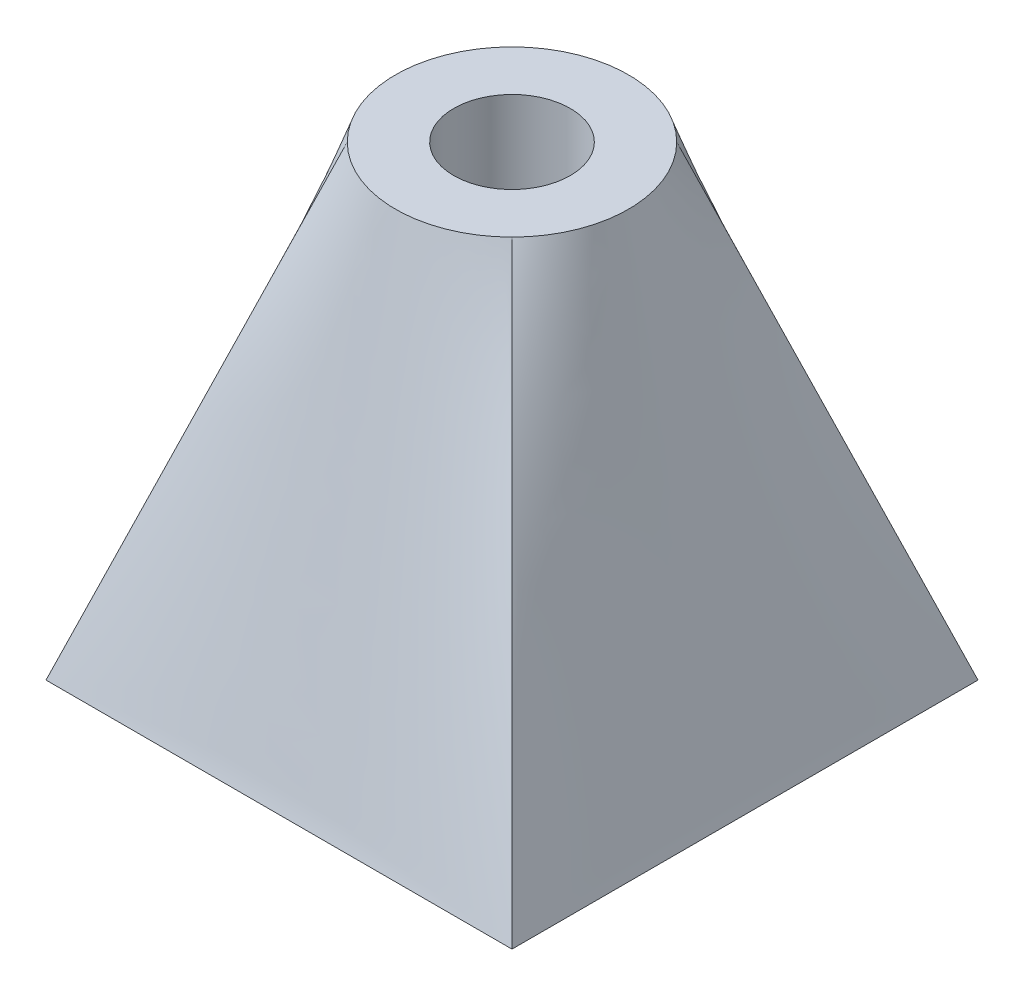
from build123d import *

# Parameters (mm, degrees)
SKETCH1_W          = 40
SKETCH1_H          = 40
SKETCH3_R          = 5
CUT_EXTRUDE1_DEPTH = 70.282032476


with BuildPart() as part:
    # Sketch1 → Loft1 section 0
    with BuildSketch(Plane(origin=(0, 0, 0), x_dir=(1, 0, 0), z_dir=(0, 1, 0))):
        with Locations((20, 20)):
            Rectangle(SKETCH1_W, SKETCH1_H)
    # Sketch2 for Loft1 → Loft1 section 1
    with BuildSketch(Plane(origin=(0, 40, 0), x_dir=(1, 0, 0), z_dir=(0, 1, 0))):
        with BuildLine():
            # circular arc as an exact rational Bezier (weights 1, cos(half-angle), 1)
            Bezier((12.928932188, 12.928932188), (20, 5.857864377), (27.071067812, 12.928932188), weights=[1, 0.707106781, 1])
            Bezier((27.071067812, 12.928932188), (34.142135623, 20), (27.071067812, 27.071067812), weights=[1, 0.707106781, 1])
            Bezier((27.071067812, 27.071067812), (20, 34.142135623), (12.928932188, 27.071067812), weights=[1, 0.707106781, 1])
            Bezier((12.928932188, 27.071067812), (5.857864377, 20), (12.928932188, 12.928932188), weights=[1, 0.707106781, 1])
        make_face()
    loft()

    # Sketch3 → Cut-Extrude1 (cut, through all)
    with BuildSketch(Plane(origin=(0, 40, 0), x_dir=(1, 0, 0), z_dir=(0, 1, 0))):
        with Locations(Location((20, 20, 0), (0, 0, 270))):
            Circle(SKETCH3_R)
    extrude(amount=-CUT_EXTRUDE1_DEPTH, mode=Mode.SUBTRACT)


solid = part.part
